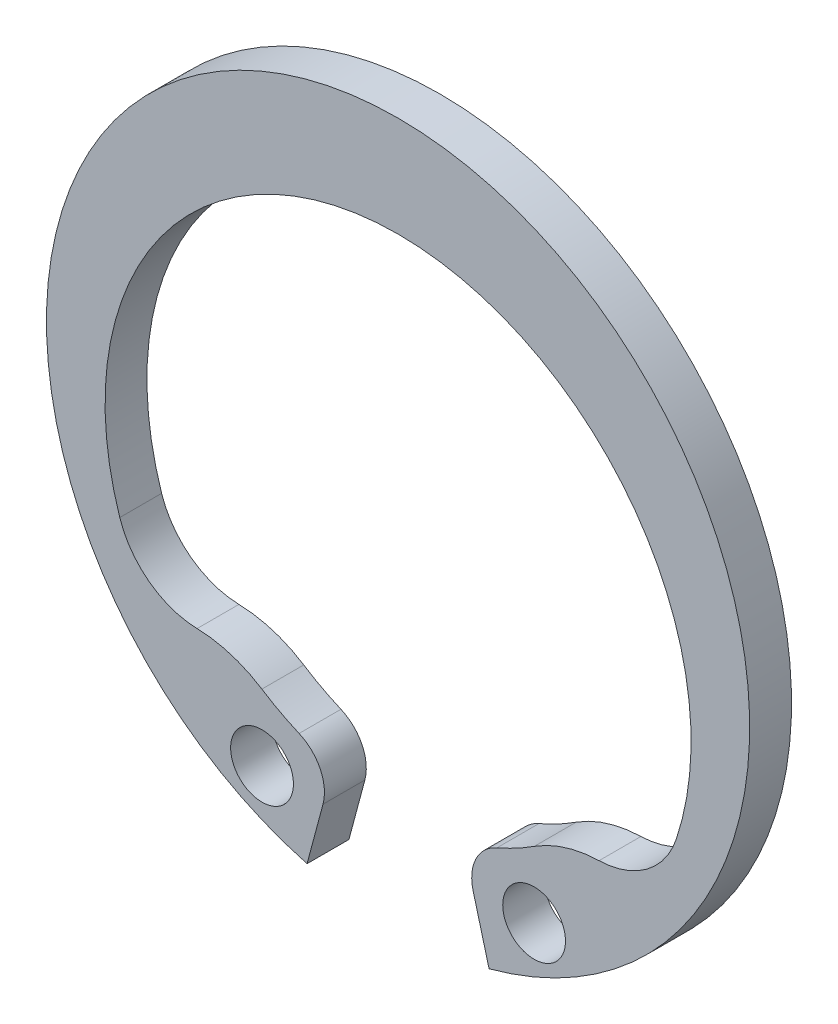
from build123d import *

# Parameters (mm, degrees)
BASE_EXTRUSION_DEPTH    = 1
ESQUISSE2_R             = 0.75
ENL_V_MAT_EXTRU_1_DEPTH = 2


with BuildPart() as part:
    # Esquisse1 → Base-Extrusion (new body)
    with BuildSketch(Plane.XY):
        with BuildLine():
            Line((-2.174079979, -8.113776941), (-1.793150944, -6.69213043))
            ThreePointArc((-1.793150944, -6.69213043), (-1.859468641, -5.996613305), (-2.364922946, -5.514266901))
            ThreePointArc((-2.364922946, -5.514266901), (-2.819293841, -5.296374443), (-3.253778531, -5.041123414))
            ThreePointArc((-3.253778531, -5.041123414), (-3.994900026, -4.695430516), (-4.80184043, -4.562720925))
            ThreePointArc((-4.80184043, -4.562720925), (-5.942925253, -4.168164446), (-6.649004393, -3.188776046))
            ThreePointArc((-6.649004393, -3.188776046), (-5.671041894, 3.103569646), (0, 6))
            Line((0, 6), (0, 8.4))
            ThreePointArc((0, 8.4), (-8.328136836, 1.096420015), (-2.174079979, -8.113776941))
        make_face()
    base_extrusion = extrude(amount=BASE_EXTRUSION_DEPTH)

    # Symétrie1: Base-Extrusion across Right Plane
    add(base_extrusion.mirror(Plane(origin=(0, 0, 0), x_dir=(0, 0, -1), z_dir=(1, 0, 0))))

    # Esquisse2 → Enlèv. mat.-Extru.1 (cut, through all)
    with BuildSketch(Plane.XY.offset(1)):
        with Locations((-3.25, -6.629165125)):
            Circle(ESQUISSE2_R)
    enl_v_mat_extru_1 = extrude(amount=-ENL_V_MAT_EXTRU_1_DEPTH, mode=Mode.SUBTRACT)

    # Symétrie2: Enlèv. mat.-Extru.1 across plane
    add(enl_v_mat_extru_1.mirror(Plane(origin=(0, 0, 0), x_dir=(0, 0, 1), z_dir=(1, 0, 0))), mode=Mode.SUBTRACT)


solid = part.part
